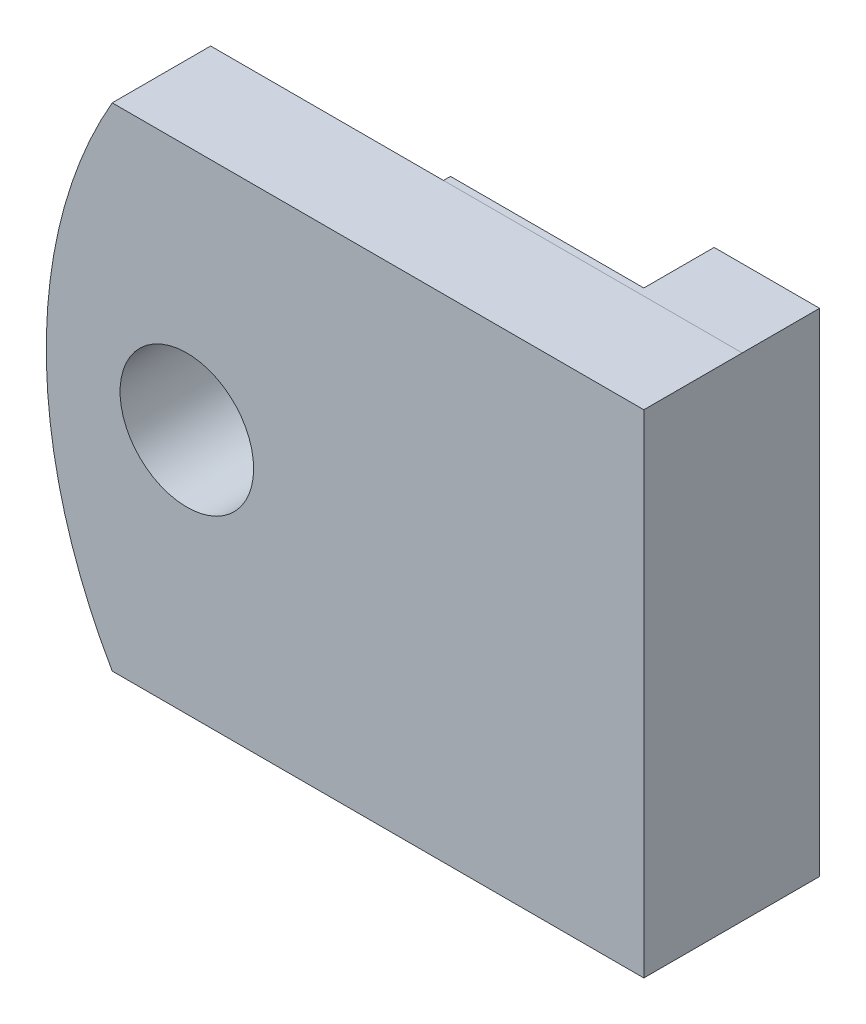
from build123d import *

# Parameters (mm, degrees)
SKETCH2_R           = 1.89991352
BOSS_EXTRUDE1_DEPTH = 2.8
SKETCH3_W           = 8.5
SKETCH3_H           = 14
BOSS_EXTRUDE2_DEPTH = 0.2
SKETCH4_W           = 3
SKETCH4_H           = 14
BOSS_EXTRUDE3_DEPTH = 2


with BuildPart() as part:
    # Sketch2 → Boss-Extrude1 (new body)
    with BuildSketch(Plane.XY):
        with BuildLine():
            Line((3, 7), (-12.123370128, 7.000155991))
            ThreePointArc((-12.123370128, 7.000155991), (-13.999397778, -1.288e-06), (-12.123378453, -7.000160797))
            Line((-12.123378453, -7.000160797), (3, -7))
            Line((3, -7), (3, 7))
        make_face()
        with Locations((-10.000000707, 1.18e-07)):
            Circle(SKETCH2_R, mode=Mode.SUBTRACT)
    extrude(amount=-BOSS_EXTRUDE1_DEPTH)

    # Sketch3 → Boss-Extrude2 (add)
    with BuildSketch(Plane(origin=(0, 0, -2.8), x_dir=(-1, 0, 0), z_dir=(0, 0, -1))):
        with Locations((1.25, 0)):
            Rectangle(SKETCH3_W, SKETCH3_H)
    extrude(amount=BOSS_EXTRUDE2_DEPTH)

    # Sketch4 → Boss-Extrude3 (add)
    with BuildSketch(Plane(origin=(0, 0, -3), x_dir=(-1, 0, 0), z_dir=(0, 0, -1))):
        with Locations((-1.5, 0)):
            Rectangle(SKETCH4_W, SKETCH4_H)
    extrude(amount=BOSS_EXTRUDE3_DEPTH)


solid = part.part
